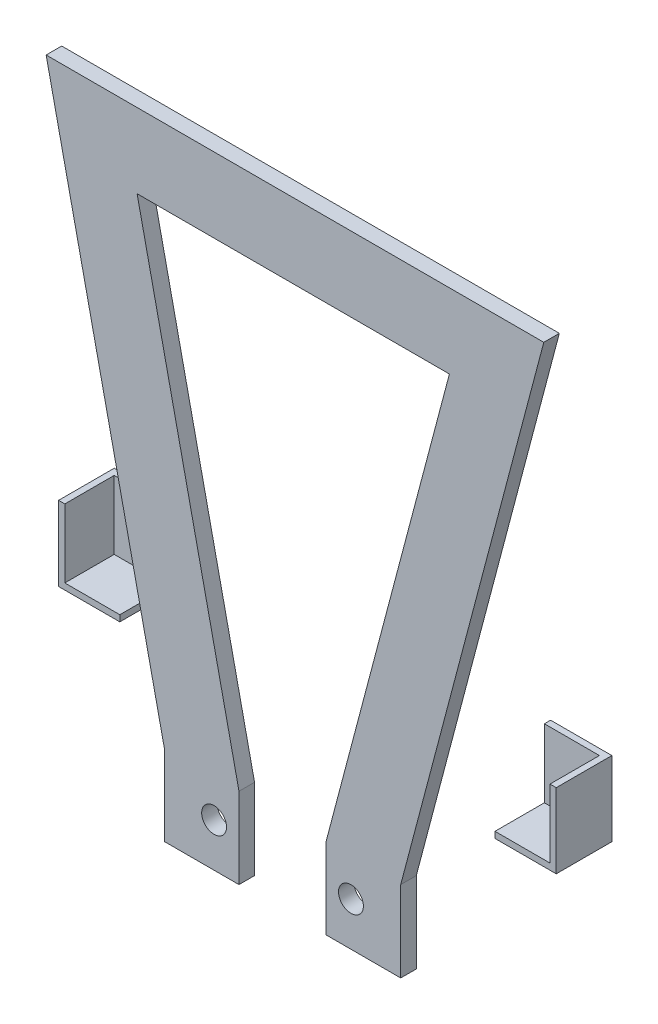
from build123d import *

# Parameters (mm, degrees)
RESSALTO_EXTRUS_O1_DEPTH       = 2.5
CORTE_EXTRUS_O1_DEPTH          = 3.5
FURO_DE_DI_METRO_4_0_4_1_D     = 4
FURO_DE_DI_METRO_4_0_4_1_DEPTH = 2.5
ESBO_O7_W                      = 9.846619962
ESBO_O7_H                      = 8.942122463
RESSALTO_EXTRUS_O2_DEPTH       = 12
CASCA1_T                       = -1


with BuildPart() as part:
    # Esboço1 → Ressalto-extrusão1 (new body)
    with BuildSketch(Plane(origin=(0, 0, -2.5), x_dir=(-1, 0, 0), z_dir=(0, 0, -1))):
        Polygon((-17, -54), (-17, -67), (21, -67), (21, -54), (40, 33), (-40, 33), align=None)
    extrude(amount=-RESSALTO_EXTRUS_O1_DEPTH)

    # Esboço2 → Corte-extrusão1 (cut, through all)
    with BuildSketch(Plane.XY):
        Polygon((-9, -67), (5, -67), (5, -54), (24.827586207, 21), (-25.379310345, 21), (-9, -54), align=None)
    extrude(amount=-CORTE_EXTRUS_O1_DEPTH, mode=Mode.SUBTRACT)

    # Furo de diâmetro Ø4.0 (4)1
    with Locations(Plane.XY):
        with Locations((-13, -60), (9, -60)):
            Hole(FURO_DE_DI_METRO_4_0_4_1_D / 2, depth=FURO_DE_DI_METRO_4_0_4_1_DEPTH)


with BuildPart() as body_2:
    # Esboço7 → Ressalto-extrusão2 (new body)
    with BuildSketch(Plane(origin=(0, -42, 0), x_dir=(1, 0, 0), z_dir=(0, 1, 0))):
        with Locations((35.076690019, 6.471061232)):
            Rectangle(ESBO_O7_W, ESBO_O7_H)
    extrude(amount=RESSALTO_EXTRUS_O2_DEPTH)

    # Casca1
    casca1_openings = [body_2.faces().sort_by_distance(p)[0] for p in [
        (35.076690019, -30, -6.471061231),
        (35.076690019, -36, -2),
        (30.153380038, -36, -6.471061231),
    ]]
    offset(amount=CASCA1_T, openings=casca1_openings, kind=Kind.INTERSECTION)


with BuildPart() as body_3:
    # Espelhar3: mirrored copy
    add(body_2.part.mirror(Plane(origin=(0, 0, 0), x_dir=(0, 0, 1), z_dir=(1, 0, 0))))


solid = Compound([part.part, body_2.part, body_3.part])
